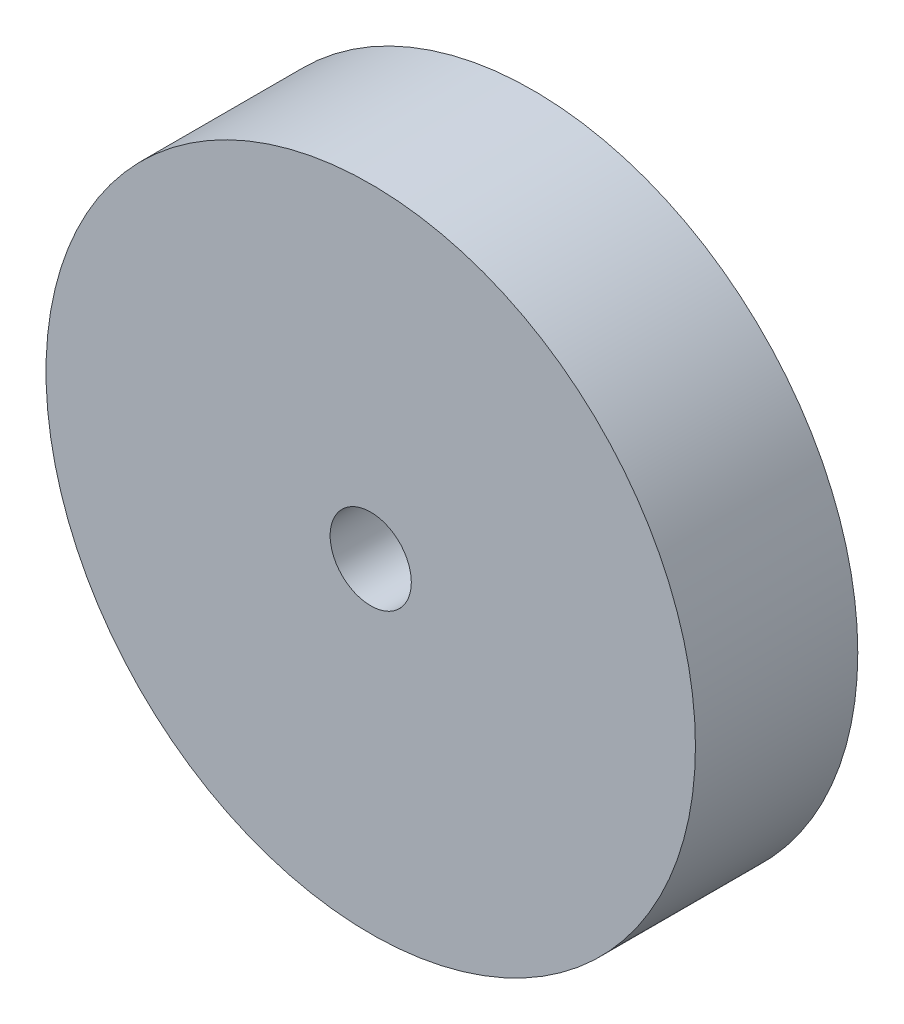
from build123d import *

# Parameters (mm, degrees)
SKETCH1_R           = 50.8
SKETCH1_R_2         = 6.35
BOSS_EXTRUDE1_DEPTH = 12.7


with BuildPart() as part:
    # Sketch1 → Boss-Extrude1 (new body, symmetric)
    with BuildSketch(Plane.XY):
        Circle(SKETCH1_R)
        Circle(SKETCH1_R_2, mode=Mode.SUBTRACT)
    extrude(amount=BOSS_EXTRUDE1_DEPTH, both=True)


solid = part.part
